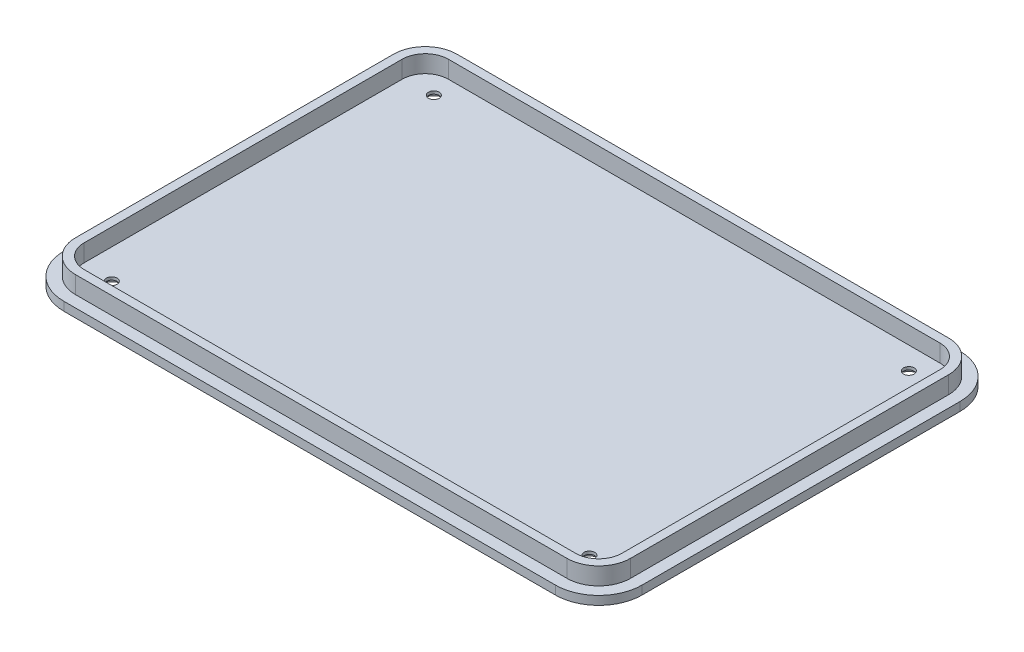
from build123d import *

# Parameters (mm, degrees)
SKETCH1_W           = 200
SKETCH1_H           = 140
BOSS_EXTRUDE1_DEPTH = 3
FILLET1_R           = 15
BOSS_EXTRUDE2_DEPTH = 6
SKETCH4_R           = 4
CUT_EXTRUDE1_DEPTH  = 2
SKETCH5_R           = 1.85
CUT_EXTRUDE2_DEPTH  = 6
SKETCH6_R           = 4
CUT_EXTRUDE3_DEPTH  = 2
SKETCH7_R           = 1.85
CUT_EXTRUDE4_DEPTH  = 2


with BuildPart() as part:
    # Sketch1 → Boss-Extrude1 (new body)
    with BuildSketch(Plane(origin=(0, 0, 0), x_dir=(1, 0, 0), z_dir=(0, 1, 0))):
        Rectangle(SKETCH1_W, SKETCH1_H)
    extrude(amount=BOSS_EXTRUDE1_DEPTH)

    # Fillet1
    fillet1_edges = [part.edges().sort_by_distance(p)[0] for p in [
        (100, 1.5, 70),
        (-100, 1.5, 70),
        (-100, 1.5, -70),
        (100, 1.5, -70),
    ]]
    fillet(fillet1_edges, radius=FILLET1_R)

    # Sketch3 → Boss-Extrude2 (add)
    with BuildSketch(Plane(origin=(0, 3, 0), x_dir=(1, 0, 0), z_dir=(0, 1, 0))):
        with BuildLine():
            Line((96, -55), (96, 55))
            ThreePointArc((96, 55), (92.778174593, 62.778174593), (85, 66))
            Line((85, 66), (-85, 66))
            ThreePointArc((-85, 66), (-92.778174593, 62.778174593), (-96, 55))
            Line((-96, 55), (-96, -55))
            ThreePointArc((-96, -55), (-92.778174593, -62.778174593), (-85, -66))
            Line((-85, -66), (85, -66))
            ThreePointArc((85, -66), (92.778174593, -62.778174593), (96, -55))
        make_face()
        with BuildLine():
            Line((85, 63), (-85, 63))
            ThreePointArc((-85, 63), (-90.656854249, 60.656854249), (-93, 55))
            Line((-93, 55), (-93, -55))
            ThreePointArc((-93, -55), (-90.656854249, -60.656854249), (-85, -63))
            Line((-85, -63), (85, -63))
            ThreePointArc((85, -63), (90.656854249, -60.656854249), (93, -55))
            Line((93, -55), (93, 55))
            ThreePointArc((93, 55), (90.656854249, 60.656854249), (85, 63))
        make_face(mode=Mode.SUBTRACT)
    extrude(amount=BOSS_EXTRUDE2_DEPTH)

    # Sketch4 → Cut-Extrude1 (cut)
    with BuildSketch(Plane(origin=(0, 0, 0), x_dir=(-1, 0, 0), z_dir=(0, -1, 0))):
        with Locations((82.73, -55.7)):
            Circle(SKETCH4_R)
    cut_extrude1 = extrude(amount=-CUT_EXTRUDE1_DEPTH, mode=Mode.SUBTRACT)

    # Mirror1: Cut-Extrude1 across plane
    add(cut_extrude1.mirror(Plane.XY), mode=Mode.SUBTRACT)

    # Sketch5 → Cut-Extrude2 (cut)
    with BuildSketch(Plane.XZ.offset(-2)):
        with Locations((-82.73, 55.7)):
            Circle(SKETCH5_R)
    cut_extrude2 = extrude(amount=-CUT_EXTRUDE2_DEPTH, mode=Mode.SUBTRACT)

    # Mirror2: Cut-Extrude2 across plane
    add(cut_extrude2.mirror(Plane.XY), mode=Mode.SUBTRACT)

    # Sketch6 → Cut-Extrude3 (cut)
    with BuildSketch(Plane(origin=(0, 0, 0), x_dir=(-1, 0, 0), z_dir=(0, -1, 0))):
        with Locations((-82, -55.25)):
            Circle(SKETCH6_R)
    cut_extrude3 = extrude(amount=-CUT_EXTRUDE3_DEPTH, mode=Mode.SUBTRACT)

    # Mirror3: Cut-Extrude3 across plane
    add(cut_extrude3.mirror(Plane.XY), mode=Mode.SUBTRACT)

    # Sketch7 → Cut-Extrude4 (cut)
    with BuildSketch(Plane(origin=(0, 2, 0), x_dir=(-1, 0, 0), z_dir=(0, -1, 0))):
        with Locations((-82, -55.25)):
            Circle(SKETCH7_R)
    cut_extrude4 = extrude(amount=-CUT_EXTRUDE4_DEPTH, mode=Mode.SUBTRACT)

    # Mirror4: Cut-Extrude4 across plane
    add(cut_extrude4.mirror(Plane.XY), mode=Mode.SUBTRACT)


solid = part.part
